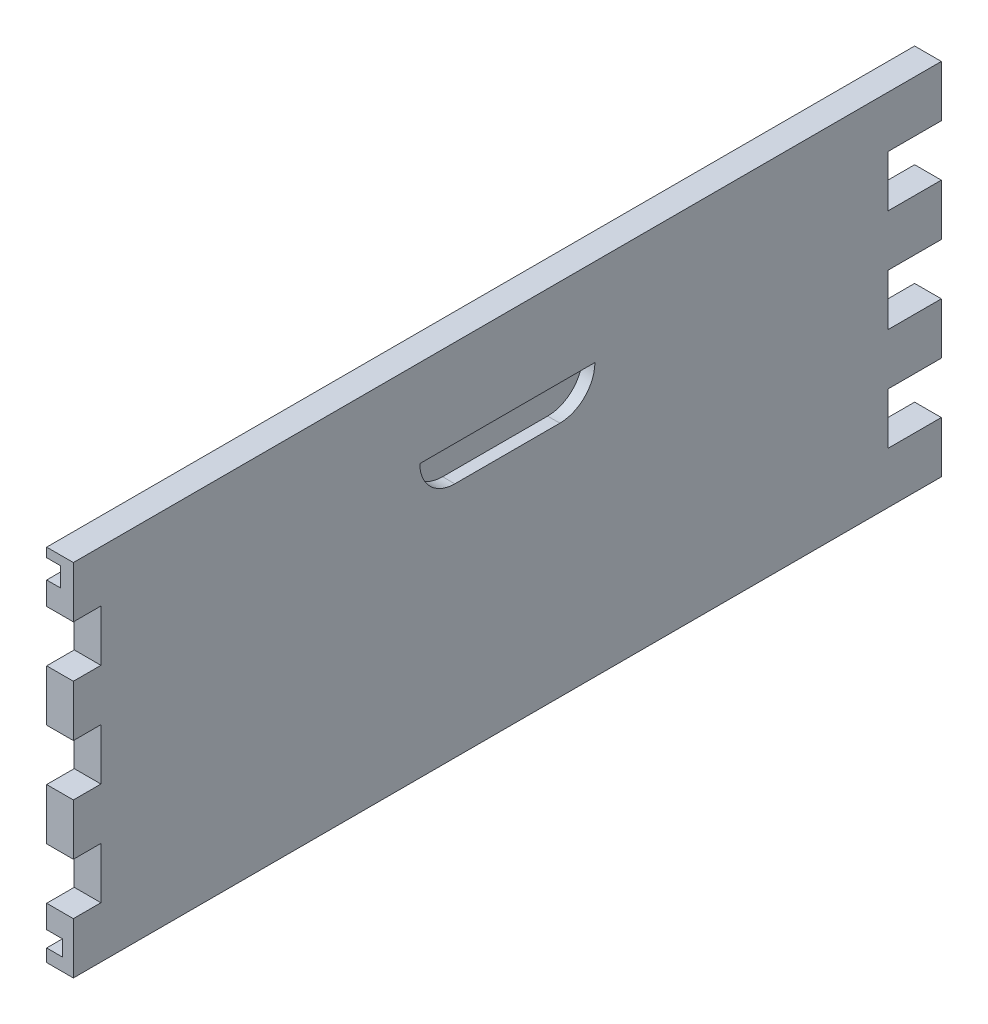
from build123d import *

# Parameters (mm, degrees)
ESQUISSE1_W             = 15.25
ESQUISSE1_H             = 205.5
BOSS_EXTRU_1_DEPTH      = 465.25
ESQUISSE2_W             = 30.5
ESQUISSE2_H             = 29.357142857
ESQUISSE2_H_2           = 29.357142858
BOSS_EXTRU_2_DEPTH      = 15.25
ENL_V_MAT_EXTRU_1_REACH = 17.25
ESQUISSE3_W             = 15.75
ESQUISSE3_H             = 29.357142857
ENL_V_MAT_EXTRU_2_DEPTH = 7
ESQUISSE5_W             = 8
ESQUISSE5_H             = 11
ENL_V_MAT_EXTRU_3_DEPTH = 160
ESQUISSE6_W             = 9.17735242
ESQUISSE6_H             = 9
ENL_V_MAT_EXTRU_4_DEPTH = 415.75
ESQUISSE7_R             = 127.5
ENL_V_MAT_EXTRU_5_DEPTH = 9
BOSS_EXTRU_3_REACH      = 18.25


with BuildPart() as part:
    # Esquisse1 → Boss.-Extru.1 (new body)
    with BuildSketch(Plane.XY):
        with Locations((155.460152838, 82.563864629)):
            Rectangle(ESQUISSE1_W, ESQUISSE1_H)
    extrude(amount=BOSS_EXTRU_1_DEPTH)

    # Esquisse2 → Boss.-Extru.2 (add)
    with BuildSketch(Plane(origin=(163.085152838, 0, 0), x_dir=(0, 0, -1), z_dir=(1, 0, 0))):
        with Locations((15.25, 170.635293201)):
            Rectangle(ESQUISSE2_W, ESQUISSE2_H)
        with Locations((15.25, 111.921007486)):
            Rectangle(ESQUISSE2_W, ESQUISSE2_H_2)
        with Locations((15.25, 53.206721771)):
            Rectangle(ESQUISSE2_W, ESQUISSE2_H)
        with Locations((15.25, -5.507563943)):
            Rectangle(ESQUISSE2_W, ESQUISSE2_H)
    extrude(amount=-BOSS_EXTRU_2_DEPTH)

    # Esquisse3 → Enlèv. mat.-Extru.1 (cut, up to next)
    with BuildSketch(Plane(origin=(163.085152838, 0, 0), x_dir=(0, 0, -1), z_dir=(1, 0, 0)), mode=Mode.PRIVATE) as enl_v_mat_extru_1_sk1:
        with Locations((-457.375, 141.278150344)):
            Rectangle(ESQUISSE3_W, ESQUISSE3_H)
    enl_v_mat_extru_1_tool1 = extrude(enl_v_mat_extru_1_sk1.sketch, amount=-ENL_V_MAT_EXTRU_1_REACH, mode=Mode.PRIVATE) & part.part
    add(enl_v_mat_extru_1_tool1.solids().sort_by_distance((163.085153, 141.27815, 457.375))[0], mode=Mode.SUBTRACT)
    # Esquisse3 → Enlèv. mat.-Extru.1 (cut, up to next)
    with BuildSketch(Plane(origin=(163.085152838, 0, 0), x_dir=(0, 0, -1), z_dir=(1, 0, 0)), mode=Mode.PRIVATE) as enl_v_mat_extru_1_sk2:
        with Locations((-457.375, 82.563864628)):
            Rectangle(ESQUISSE3_W, ESQUISSE3_H)
    enl_v_mat_extru_1_tool2 = extrude(enl_v_mat_extru_1_sk2.sketch, amount=-ENL_V_MAT_EXTRU_1_REACH, mode=Mode.PRIVATE) & part.part
    add(enl_v_mat_extru_1_tool2.solids().sort_by_distance((163.085153, 82.563865, 457.375))[0], mode=Mode.SUBTRACT)
    # Esquisse3 → Enlèv. mat.-Extru.1 (cut, up to next)
    with BuildSketch(Plane(origin=(163.085152838, 0, 0), x_dir=(0, 0, -1), z_dir=(1, 0, 0)), mode=Mode.PRIVATE) as enl_v_mat_extru_1_sk3:
        with Locations((-457.375, 23.849578915)):
            Rectangle(ESQUISSE3_W, ESQUISSE3_H)
    enl_v_mat_extru_1_tool3 = extrude(enl_v_mat_extru_1_sk3.sketch, amount=-ENL_V_MAT_EXTRU_1_REACH, mode=Mode.PRIVATE) & part.part
    add(enl_v_mat_extru_1_tool3.solids().sort_by_distance((163.085153, 23.849579, 457.375))[0], mode=Mode.SUBTRACT)

    # Esquisse4 → Enlèv. mat.-Extru.2 (cut)
    with BuildSketch(Plane(origin=(163.085152838, 0, 0), x_dir=(0, 0, -1), z_dir=(1, 0, 0))):
        with BuildLine():
            Line((-267.375, 135.313864629), (-167.375, 135.313864629))
            ThreePointArc((-167.375, 135.313864629), (-173.232864376, 121.171729005), (-187.375, 115.313864629))
            Line((-187.375, 115.313864629), (-247.375, 115.313864629))
            ThreePointArc((-247.375, 115.313864629), (-261.517135624, 121.171729005), (-267.375, 135.313864629))
        make_face()
    extrude(amount=-ENL_V_MAT_EXTRU_2_DEPTH, mode=Mode.SUBTRACT)

    # Esquisse5 → Enlèv. mat.-Extru.3 (cut)
    with BuildSketch(Plane.XY.offset(465.25)):
        with Locations((151.835152838, 174.563864629)):
            Rectangle(ESQUISSE5_W, ESQUISSE5_H)
    extrude(amount=-ENL_V_MAT_EXTRU_3_DEPTH, mode=Mode.SUBTRACT)

    # Esquisse6 → Enlèv. mat.-Extru.4 (cut)
    with BuildSketch(Plane.XY.offset(465.25)):
        with Locations((152.423829048, -8.436135371)):
            Rectangle(ESQUISSE6_W, ESQUISSE6_H)
    extrude(amount=-ENL_V_MAT_EXTRU_4_DEPTH, mode=Mode.SUBTRACT)

    # Esquisse7 → Enlèv. mat.-Extru.5 (cut)
    with BuildSketch(Plane.XZ.offset(3.936135371)):
        with Locations((29.512505258, 49.5)):
            Circle(ESQUISSE7_R)
    extrude(amount=ENL_V_MAT_EXTRU_5_DEPTH, mode=Mode.SUBTRACT)

    # Esquisse8 → Boss.-Extru.3 (add, up to next)
    with BuildSketch(Plane(origin=(0, 169.063864629, 0), x_dir=(1, 0, 0), z_dir=(0, 1, 0)), mode=Mode.PRIVATE) as boss_extru_3_sk1:
        with BuildLine():
            Line((147.835152838, -305.25), (155.835152838, -305.25))
            Line((155.835152838, -305.25), (155.835152838, -332.922407507))
            ThreePointArc((155.835152838, -332.922407507), (153.795024483, -318.519611448), (147.835152838, -305.25))
        make_face()
    boss_extru_3_tool1 = extrude(boss_extru_3_sk1.sketch, amount=BOSS_EXTRU_3_REACH, mode=Mode.PRIVATE) - part.part
    add(boss_extru_3_tool1.solids().sort_by_distance((153.470601, 169.063865, 312.056849))[0])


solid = part.part
